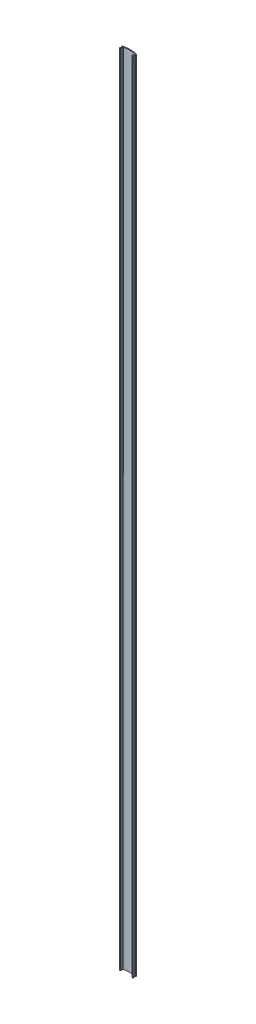
from build123d import *

# Parameters (mm, degrees)
SALIENTE_EXTRUIR1_DEPTH = 920


with BuildPart() as part:
    # Croquis1 → Saliente-Extruir1 (new body)
    with BuildSketch(Plane(origin=(0, 0, 0), x_dir=(1, 0, 0), z_dir=(0, 1, 0))):
        with BuildLine():
            Line((-27.04570475, 0.111036701), (-27.04570475, -0.9709854))
            ThreePointArc((-27.04570475, -0.9709854), (-27.106772974, -1.136359948), (-27.260665216, -1.222355571))
            ThreePointArc((-27.260665216, -1.222355571), (-27.673358623, -1.810535113), (-27.070917054, -2.202115474))
            Line((-27.070917054, -2.202115474), (-26.38570475, -2.202115474))
            ThreePointArc((-26.38570475, -2.202115474), (-26.173572716, -2.114247508), (-26.08570475, -1.902115474))
            Line((-26.08570475, -1.902115474), (-26.08570475, 0.111036701))
            ThreePointArc((-26.08570475, 0.111036701), (-26.092347771, 0.237887611), (-26.112204161, 0.36335078))
            ThreePointArc((-26.112204161, 0.36335078), (-26.06688189, 0.594292482), (-25.868853352, 0.721465107))
            ThreePointArc((-25.868853352, 0.721465107), (-19.52570475, 1.480091061), (-13.182556148, 0.721465107))
            ThreePointArc((-13.182556148, 0.721465107), (-12.984527611, 0.594292482), (-12.93920534, 0.36335078))
            ThreePointArc((-12.93920534, 0.36335078), (-12.959061729, 0.237887611), (-12.96570475, 0.111036701))
            Line((-12.96570475, 0.111036701), (-12.96570475, -1.902115474))
            ThreePointArc((-12.96570475, -1.902115474), (-12.877836785, -2.114247508), (-12.66570475, -2.202115474))
            Line((-12.66570475, -2.202115474), (-11.980492447, -2.202115474))
            ThreePointArc((-11.980492447, -2.202115474), (-11.378050878, -1.810535113), (-11.790744285, -1.222355571))
            ThreePointArc((-11.790744285, -1.222355571), (-11.944636526, -1.136359948), (-12.00570475, -0.9709854))
            Line((-12.00570475, -0.9709854), (-12.00570475, 0.111036701))
            ThreePointArc((-12.00570475, 0.111036701), (-11.943640246, 0.277569223), (-11.787723385, 0.362862925))
            ThreePointArc((-11.787723385, 0.362862925), (-11.352050184, 0.596107617), (-11.166986384, 1.054327667))
            ThreePointArc((-11.166986384, 1.054327667), (-11.230212618, 1.249640519), (-11.40422216, 1.358568688))
            ThreePointArc((-11.40422216, 1.358568688), (-19.52570475, 2.441214001), (-27.64718734, 1.358568688))
            ThreePointArc((-27.64718734, 1.358568688), (-27.821196883, 1.249640519), (-27.884423117, 1.054327667))
            ThreePointArc((-27.884423117, 1.054327667), (-27.699359317, 0.596107617), (-27.263686116, 0.362862925))
            ThreePointArc((-27.263686116, 0.362862925), (-27.107769254, 0.277569223), (-27.04570475, 0.111036701))
        make_face()
    extrude(amount=SALIENTE_EXTRUIR1_DEPTH)


solid = part.part
